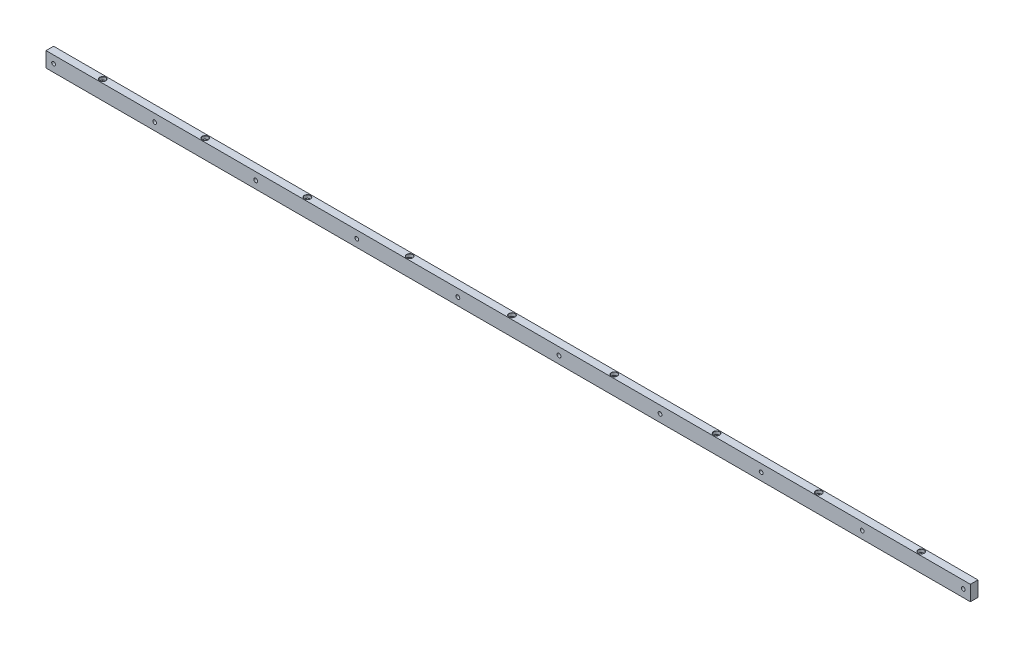
from build123d import *

# Parameters (mm, degrees)
SKETCH1_W           = 1549.4
SKETCH1_H           = 25.4
SKETCH1_R           = 3.175
BOSS_EXTRUDE1_DEPTH = 12.7
LPATTERN1_COUNT     = 9
LPATTERN1_PITCH     = 171.45


with BuildPart() as part:
    # Sketch1 → Boss-Extrude1 (new body)
    with BuildSketch(Plane.XY):
        with Locations((774.7, 12.7)):
            Rectangle(SKETCH1_W, SKETCH1_H)
        with Locations((12.7, 12.7)):
            Circle(SKETCH1_R, mode=Mode.SUBTRACT)
        with Locations((182.118, 12.7)):
            Circle(SKETCH1_R, mode=Mode.SUBTRACT)
        with Locations((351.536, 12.7)):
            Circle(SKETCH1_R, mode=Mode.SUBTRACT)
        with Locations((520.954, 12.7)):
            Circle(SKETCH1_R, mode=Mode.SUBTRACT)
        with Locations((690.372, 12.7)):
            Circle(SKETCH1_R, mode=Mode.SUBTRACT)
        with Locations((859.79, 12.7)):
            Circle(SKETCH1_R, mode=Mode.SUBTRACT)
        with Locations((1029.208, 12.7)):
            Circle(SKETCH1_R, mode=Mode.SUBTRACT)
        with Locations((1198.626, 12.7)):
            Circle(SKETCH1_R, mode=Mode.SUBTRACT)
        with Locations((1368.044, 12.7)):
            Circle(SKETCH1_R, mode=Mode.SUBTRACT)
        with Locations((1537.462, 12.7)):
            Circle(SKETCH1_R, mode=Mode.SUBTRACT)
    extrude(amount=-BOSS_EXTRUDE1_DEPTH)

    # Sketch3 → CBORE for #0 Binding Head Machine Screw1 (revolve, cut)
    with BuildSketch(Plane(origin=(88.9, 25.4, -6.35), x_dir=(0, 0, 1), z_dir=(1, 0, 0))):
        Polygon((0, 0), (0, 25.4), (2.7559, 25.4), (2.7559, 5.08), (4.953, 5.08), (4.953, 0.2413), (5.1943, 0), align=None)
    cbore_for_0_binding_head_machine_screw1 = revolve(axis=Axis((88.9, 31.75, -6.35), (0, -1, 0)), mode=Mode.SUBTRACT)

    # LPattern1: CBORE for #0 Binding Head Machine Screw1 ×9
    with Locations(*[(i * LPATTERN1_PITCH, 0, 0) for i in range(1, LPATTERN1_COUNT)]):
        add(cbore_for_0_binding_head_machine_screw1, mode=Mode.SUBTRACT)


solid = part.part
